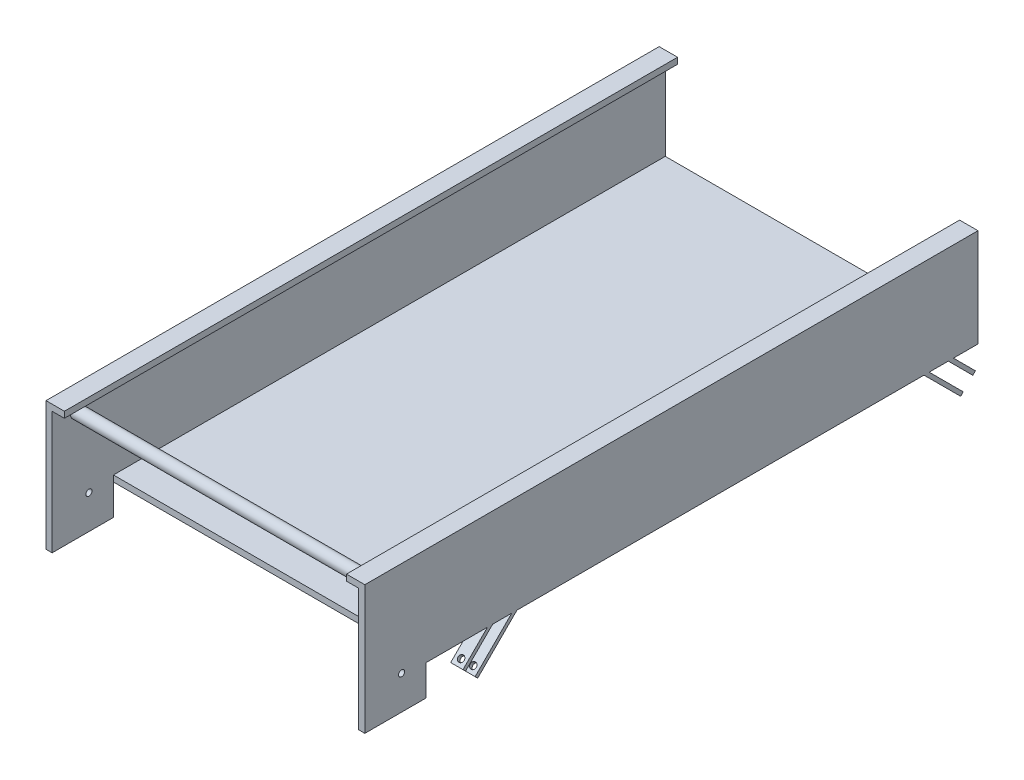
from build123d import *

# Parameters (mm, degrees)
BOSS_EXTRUDE2_DEPTH     = 500
SKETCH3_W               = 250
SKETCH3_H               = 50
CUT_EXTRUDE1_DEPTH      = 6
SKETCH5_W               = 50
SKETCH5_H               = 25
BOSS_EXTRUDE3_DEPTH     = 5
SKETCH7_W               = 50
SKETCH7_H               = 25
BOSS_EXTRUDE4_DEPTH     = 5
SKETCH8_R               = 2.5
CUT_EXTRUDE4_DEPTH      = 256
CUT_EXTRUDE4_DEPTH_BACK = 6
SKETCH11_R              = 5
BOSS_EXTRUDE15_DEPTH    = 250
BOSS_EXTRUDE16_DEPTH    = 10
BOSS_EXTRUDE17_DEPTH    = 10
CUT_EXTRUDE5_START      = -17
SKETCH30_R              = 2.5
CUT_EXTRUDE5_DEPTH      = 306.484848098
SKETCH31_R              = 2.5
CUT_EXTRUDE6_DEPTH      = 17


with BuildPart() as part:
    # Sketch2 → Boss-Extrude2 (new body)
    with BuildSketch(Plane.XY):
        Polygon((-130, 0), (130, 0), (130, 80), (115, 80), (115, 75), (125, 75), (125, 5), (-125, 5), (-125, 75), (-115, 75), (-115, 80), (-130, 80), align=None)
    extrude(amount=BOSS_EXTRUDE2_DEPTH)

    # Sketch3 → Cut-Extrude1 (cut, through all)
    with BuildSketch(Plane(origin=(0, 5, 0), x_dir=(1, 0, 0), z_dir=(0, 1, 0))):
        with Locations((0, -475)):
            Rectangle(SKETCH3_W, SKETCH3_H)
    extrude(amount=-CUT_EXTRUDE1_DEPTH, mode=Mode.SUBTRACT)

    # Sketch5 → Boss-Extrude3 (add)
    with BuildSketch(Plane.ZY.offset(-125)):
        with Locations((475, -12.5)):
            Rectangle(SKETCH5_W, SKETCH5_H)
    extrude(amount=-BOSS_EXTRUDE3_DEPTH)

    # Sketch7 → Boss-Extrude4 (add)
    with BuildSketch(Plane(origin=(-125, 0, 0), x_dir=(0, 0, -1), z_dir=(1, 0, 0))):
        with Locations((-475, -12.5)):
            Rectangle(SKETCH7_W, SKETCH7_H)
    extrude(amount=-BOSS_EXTRUDE4_DEPTH)

    # Sketch8 → Cut-Extrude4 (cut, two sides)
    with BuildSketch(Plane.ZY.offset(-125)) as cut_extrude4_sk:
        with Locations((470, 2.5)):
            Circle(SKETCH8_R)
    extrude(amount=CUT_EXTRUDE4_DEPTH, mode=Mode.SUBTRACT)
    extrude(cut_extrude4_sk.sketch, amount=-CUT_EXTRUDE4_DEPTH_BACK, mode=Mode.SUBTRACT)

    # Sketch11 → Boss-Extrude15 (add)
    with BuildSketch(Plane.ZY.offset(-125)):
        with Locations((480, 65)):
            Circle(SKETCH11_R)
    extrude(amount=BOSS_EXTRUDE15_DEPTH)

    # Sketch27 → Boss-Extrude16 (add)
    with BuildSketch(Plane(origin=(130, 0, 0), x_dir=(0, 0, -1), z_dir=(1, 0, 0))):
        Polygon((-20, 0), (-2.121320344, -17.878679656), (-4.242640687, -20), (-24.242640687, 0), align=None)
        Polygon((-39.798989873, 0), (-12.02081528, -27.778174593), (-14.142135624, -29.899494937), (-44.04163056, 0), align=None)
    boss_extrude16 = extrude(amount=-BOSS_EXTRUDE16_DEPTH)

    # Mirror1: Boss-Extrude16 across plane
    add(boss_extrude16.mirror(Plane.ZY))

    # Sketch29 → Boss-Extrude17 (add)
    with BuildSketch(Plane(origin=(130, 0, 0), x_dir=(0, 0, -1), z_dir=(1, 0, 0))):
        Polygon((-400, 0), (-420, -20), (-417.878679656, -22.121320344), (-395.757359313, 0), align=None)
        Polygon((-380.201010127, 0), (-410.100505063, -29.899494937), (-407.97918472, -32.02081528), (-375.95836944, 0), align=None)
    boss_extrude17 = extrude(amount=-BOSS_EXTRUDE17_DEPTH)

    # Mirror2: Boss-Extrude17 across plane
    add(boss_extrude17.mirror(Plane.ZY))

    # Sketch30 → Cut-Extrude5 (cut)
    with BuildSketch(Plane(origin=(0, 187.97918472, 187.97918472), x_dir=(1, 0, 0), z_dir=(0, -0.707106781, -0.707106781)).offset(CUT_EXTRUDE5_START)):
        with Locations((125, 306.126983722)):
            Circle(SKETCH30_R)
    cut_extrude5 = extrude(amount=CUT_EXTRUDE5_DEPTH, mode=Mode.SUBTRACT)

    # Mirror3: Cut-Extrude5 across plane
    add(cut_extrude5.mirror(Plane.ZY), mode=Mode.SUBTRACT)

    # Sketch31 → Cut-Extrude6 (cut)
    with BuildSketch(Plane(origin=(0, -22.02081528, 22.02081528), x_dir=(1, 0, 0), z_dir=(0, -0.707106781, 0.707106781))):
        with Locations((125, -6.142135624)):
            Circle(SKETCH31_R)
    cut_extrude6 = extrude(amount=-CUT_EXTRUDE6_DEPTH, mode=Mode.SUBTRACT)

    # Mirror5: Cut-Extrude6 across plane
    add(cut_extrude6.mirror(Plane.ZY), mode=Mode.SUBTRACT)


solid = part.part
